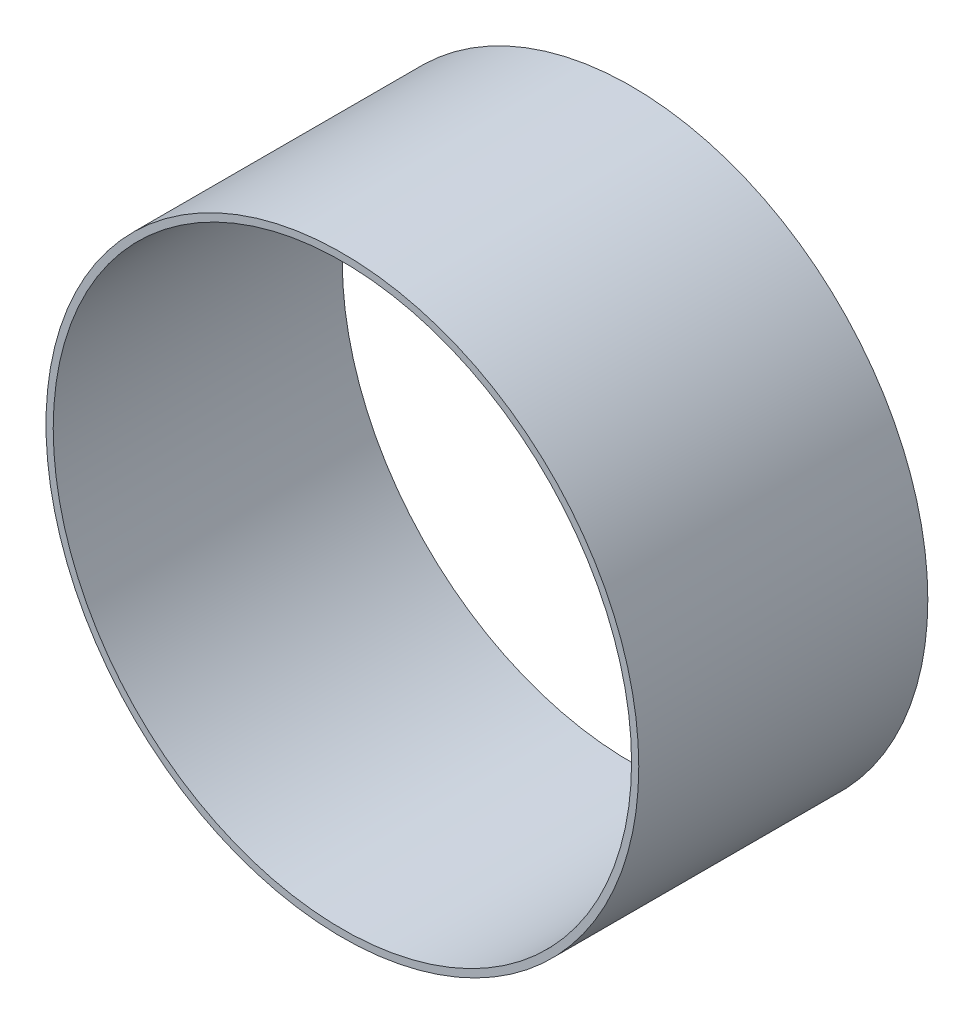
from build123d import *

# Parameters (mm, degrees)
SKETCH1_R           = 41.016
SKETCH1_R_2         = 40.016
EXTRUDE_THIN1_DEPTH = 20


with BuildPart() as part:
    # Sketch1 → Extrude-Thin1 (new body, symmetric)
    with BuildSketch(Plane.XY):
        Circle(SKETCH1_R)
        Circle(SKETCH1_R_2, mode=Mode.SUBTRACT)
    extrude(amount=EXTRUDE_THIN1_DEPTH, both=True)


solid = part.part
